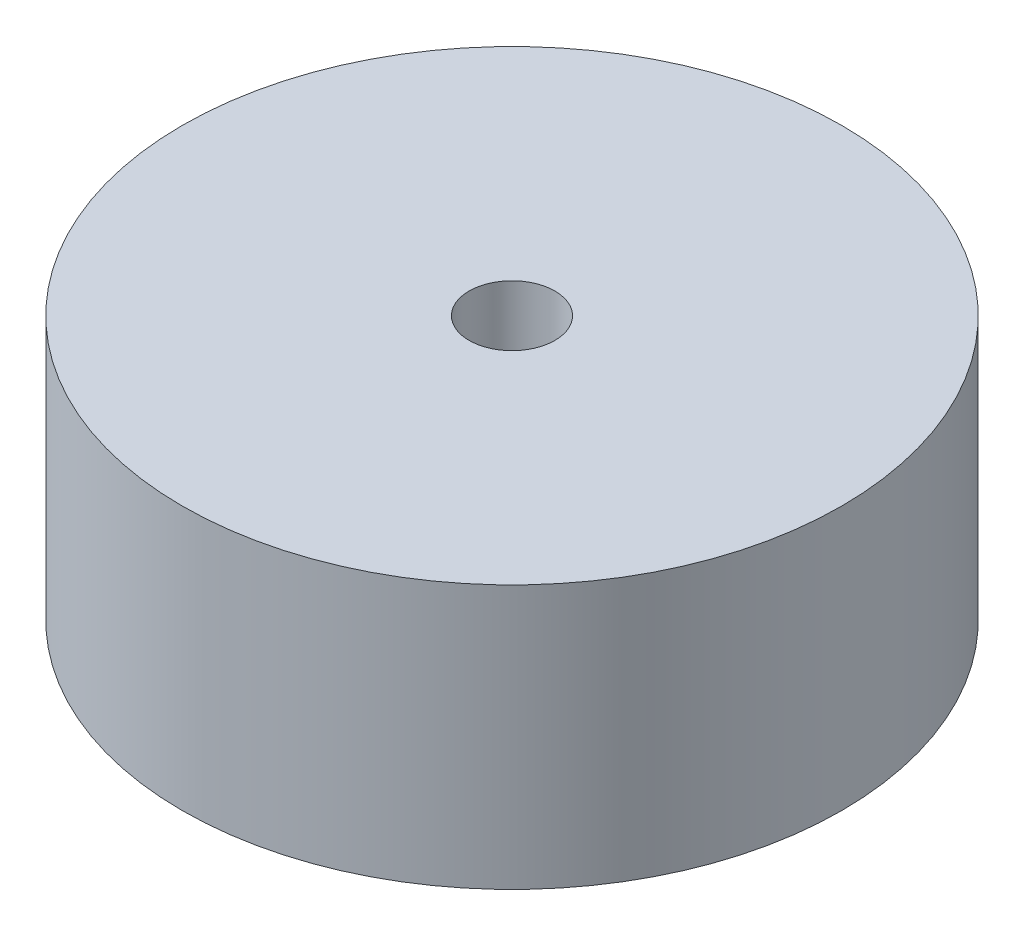
from build123d import *

# Parameters (mm, degrees)
SKETCH1_R                  = 50
BOSS_EXTRUDE1_DEPTH        = 40
F_13_0_13_DIAMETER_HOLE1_D = 13


with BuildPart() as part:
    # Sketch1 → Boss-Extrude1 (new body)
    with BuildSketch(Plane(origin=(0, 0, 0), x_dir=(1, 0, 0), z_dir=(0, 1, 0))):
        Circle(SKETCH1_R)
    extrude(amount=BOSS_EXTRUDE1_DEPTH)

    # Ø13.0 (13) Diameter Hole1 (through all)
    with Locations(Plane(origin=(0, 0, 0), x_dir=(-1, 0, 0), z_dir=(0, -1, 0))):
        with Locations((0, 0)):
            Hole(F_13_0_13_DIAMETER_HOLE1_D / 2)


solid = part.part
